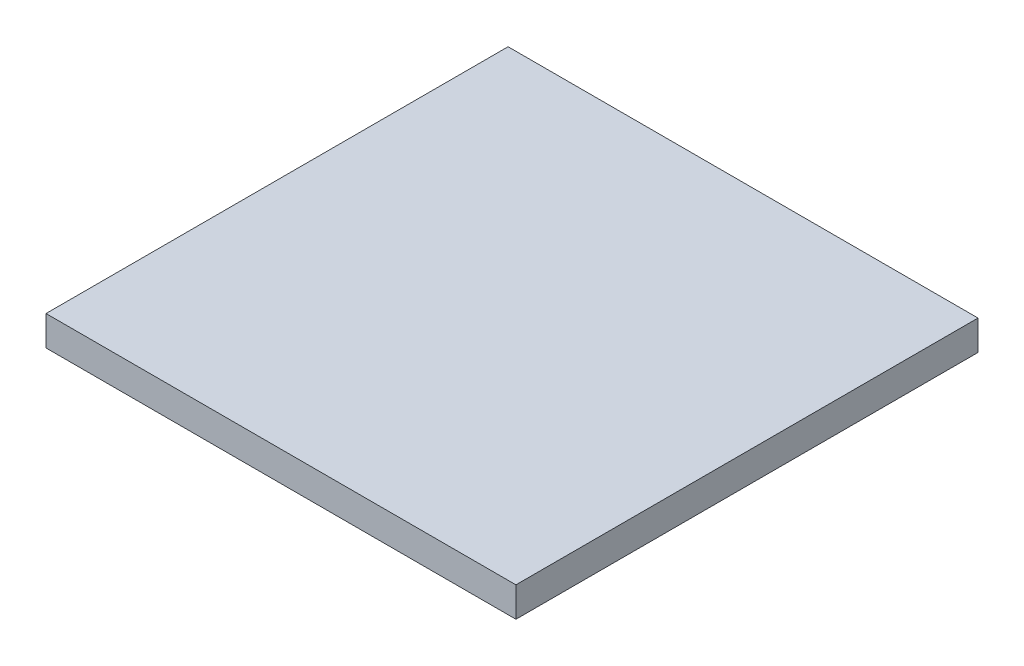
from build123d import *

# Parameters (mm, degrees)
SKETCH1_W           = 600
SKETCH1_H           = 590
BOSS_EXTRUDE1_DEPTH = 38.1


with BuildPart() as part:
    # Sketch1 → Boss-Extrude1 (new body)
    with BuildSketch(Plane(origin=(0, 0, 0), x_dir=(1, 0, 0), z_dir=(0, 1, 0))):
        Rectangle(SKETCH1_W, SKETCH1_H)
    extrude(amount=BOSS_EXTRUDE1_DEPTH)


solid = part.part
